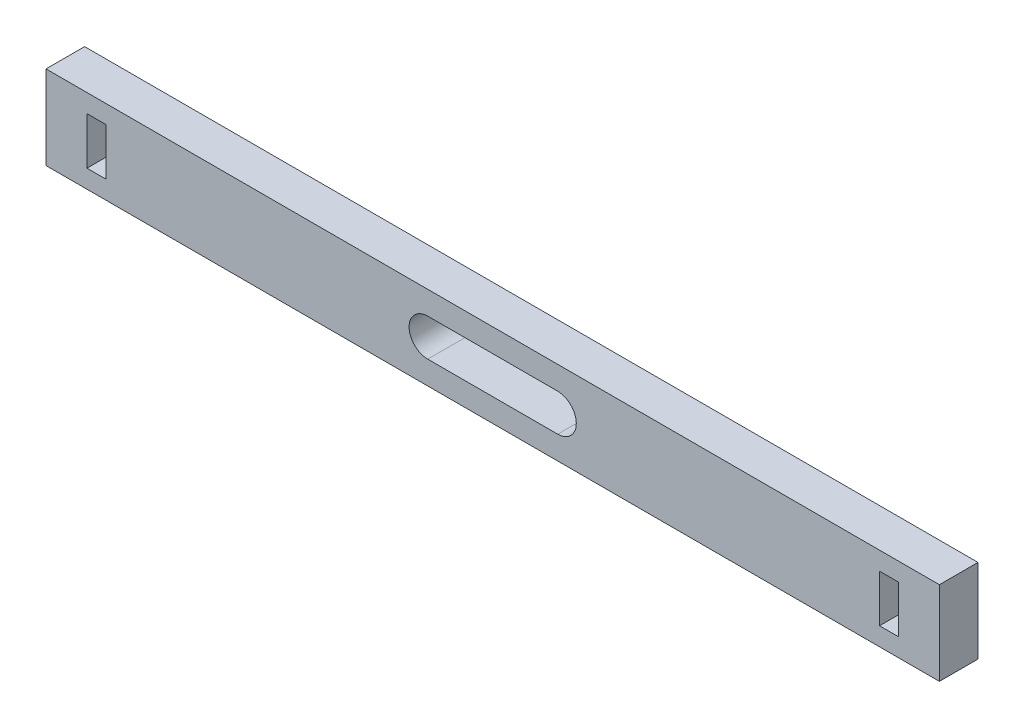
from build123d import *

# Parameters (mm, degrees)
SKETCH1_W           = 72
SKETCH1_H           = 6.748944735
SKETCH1_W_2         = 1.524
SKETCH1_H_2         = 3.81
BOSS_EXTRUDE1_DEPTH = 3.1115


with BuildPart() as part:
    # Sketch1 → Boss-Extrude1 (new body)
    with BuildSketch(Plane.XY):
        with Locations((-0.032699801, 0.340407728)):
            Rectangle(SKETCH1_W, SKETCH1_H)
        with Locations((31.905300199, 0.340407728)):
            Rectangle(SKETCH1_W_2, SKETCH1_H_2, mode=Mode.SUBTRACT)
        with Locations((-31.970699801, 0.340407728)):
            Rectangle(SKETCH1_W_2, SKETCH1_H_2, mode=Mode.SUBTRACT)
        with BuildLine():
            Line((-5.27007754, 1.840407728), (5.204677939, 1.840407728))
            ThreePointArc((5.204677939, 1.840407728), (6.704677939, 0.340407728), (5.204677939, -1.159592272))
            Line((5.204677939, -1.159592272), (-5.27007754, -1.159592272))
            ThreePointArc((-5.27007754, -1.159592272), (-6.77007754, 0.340407728), (-5.27007754, 1.840407728))
        make_face(mode=Mode.SUBTRACT)
    extrude(amount=BOSS_EXTRUDE1_DEPTH)


solid = part.part
